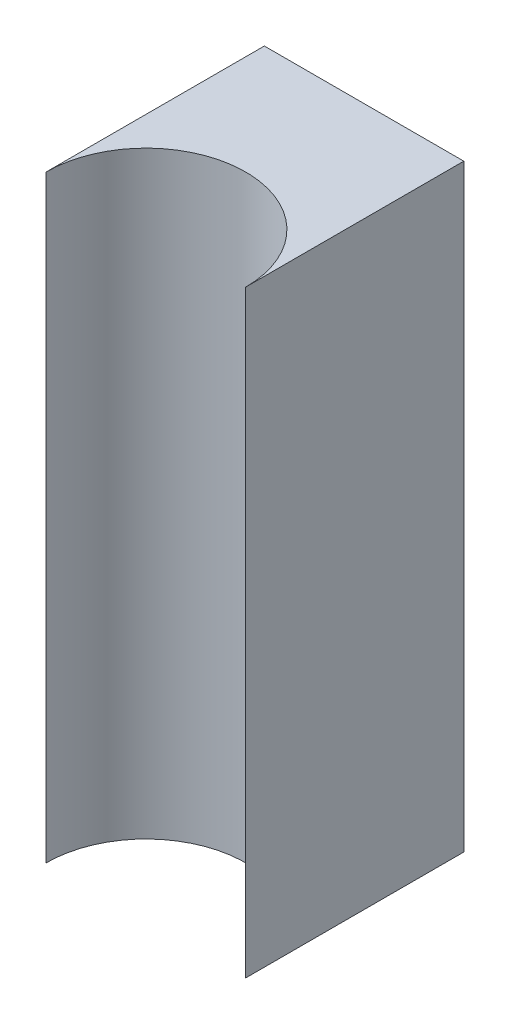
from build123d import *

# Parameters (mm, degrees)
SKETCH1_W           = 15
SKETCH1_H           = 45
BOSS_EXTRUDE1_DEPTH = 22
CUT_EXTRUDE1_DEPTH  = 46


with BuildPart() as part:
    # Sketch1 → Boss-Extrude1 (new body)
    with BuildSketch(Plane.XY):
        with Locations((171.5, 0)):
            Rectangle(SKETCH1_W, SKETCH1_H)
    extrude(amount=BOSS_EXTRUDE1_DEPTH)

    # Sketch2 → Cut-Extrude1 (cut, through all)
    with BuildSketch(Plane.XZ.offset(22.5)):
        with BuildLine():
            ThreePointArc((166.503982526, 22), (164.654558778, 19.470570526), (164, 16.406270528))
            ThreePointArc((164, 16.406270528), (171.5, 8.906270528), (179, 16.406270528))
            ThreePointArc((179, 16.406270528), (178.345441222, 19.470570526), (176.496017474, 22))
            Line((176.496017474, 22), (166.503982526, 22))
        make_face()
        with BuildLine():
            ThreePointArc((176.496017474, 22), (171.5, 23.906270528), (166.503982526, 22))
            Line((166.503982526, 22), (176.496017474, 22))
        make_face()
        with BuildLine():
            Line((164, 22), (164, 16.406270528))
            ThreePointArc((164, 16.406270528), (164.654558778, 19.470570526), (166.503982526, 22))
            Line((166.503982526, 22), (164, 22))
        make_face()
        with BuildLine():
            ThreePointArc((176.496017474, 22), (178.345441222, 19.470570526), (179, 16.406270528))
            Line((179, 16.406270528), (179, 22))
            Line((179, 22), (176.496017474, 22))
        make_face()
    extrude(amount=-CUT_EXTRUDE1_DEPTH, mode=Mode.SUBTRACT)


solid = part.part
